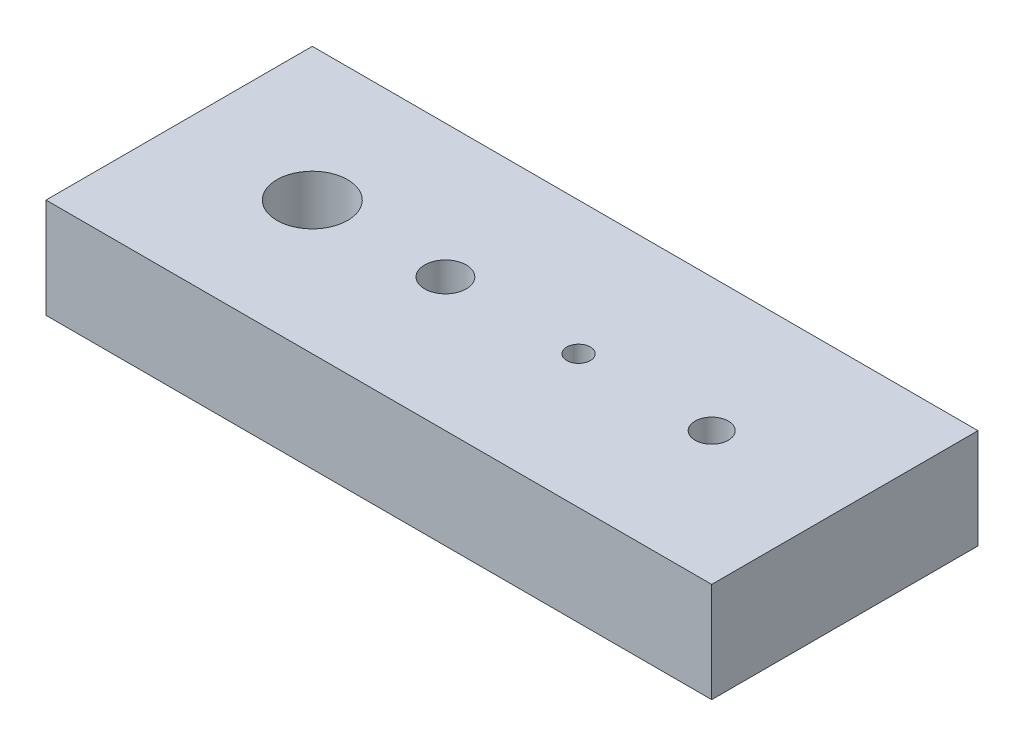
from build123d import *

# Parameters (mm, degrees)
SKETCH1_W                   = 127
SKETCH1_H                   = 19.05
BOSS_EXTRUDE1_DEPTH         = 50.8
F_1_2_CLEARANCE_HOLE1_D     = 13.49248
F_3_8_16_TAPPED_HOLE1_D     = 7.9375
F_12_24_TAPPED_HOLE1_D      = 4.4958
F_1_4_0_25_DIAMETER_HOLE1_D = 6.35


with BuildPart() as part:
    # Sketch1 → Boss-Extrude1 (new body)
    with BuildSketch(Plane.XY):
        with Locations((63.5, 9.525)):
            Rectangle(SKETCH1_W, SKETCH1_H)
    extrude(amount=BOSS_EXTRUDE1_DEPTH)

    # 1/2 Clearance Hole1 (through all)
    with Locations(Plane(origin=(0, 19.05, 0), x_dir=(1, 0, 0), z_dir=(0, 1, 0))):
        with Locations((25.4, -25.4)):
            Hole(F_1_2_CLEARANCE_HOLE1_D / 2)

    # 3/8-16 Tapped Hole1 (through all)
    with Locations(Plane(origin=(0, 19.05, 0), x_dir=(1, 0, 0), z_dir=(0, 1, 0))):
        with Locations((50.8, -25.4)):
            Hole(F_3_8_16_TAPPED_HOLE1_D / 2)

    # #12-24 Tapped Hole1 (through all)
    with Locations(Plane(origin=(0, 19.05, 0), x_dir=(1, 0, 0), z_dir=(0, 1, 0))):
        with Locations((76.2, -25.4)):
            Hole(F_12_24_TAPPED_HOLE1_D / 2)

    # 1/4 (0.25) Diameter Hole1 (through all)
    with Locations(Plane(origin=(0, 19.05, 0), x_dir=(1, 0, 0), z_dir=(0, 1, 0))):
        with Locations((101.6, -25.4)):
            Hole(F_1_4_0_25_DIAMETER_HOLE1_D / 2)


solid = part.part
